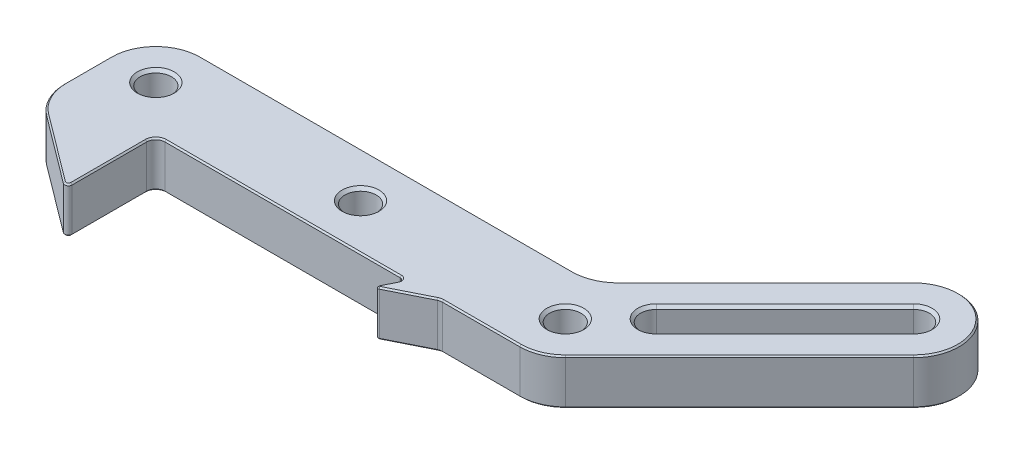
from build123d import *

# Parameters (mm, degrees)
SKETCH1_R           = 2.1828125
BOSS_EXTRUDE1_DEPTH = 6.35
CHAMFER2_SIZE       = 0.396875
CHAMFER3_SIZE       = 0.1984375


with BuildPart() as part:
    # Sketch1 → Boss-Extrude1 (new body)
    with BuildSketch(Plane(origin=(0, 0, 0), x_dir=(1, 0, 0), z_dir=(0, 1, 0))):
        with BuildLine():
            Line((-50.8, -7.62), (-50.8, -18.034))
            ThreePointArc((-50.8, -18.034), (-51.080815493, -18.488369013), (-51.6128, -18.4404))
            Line((-51.6128, -18.4404), (-60.9601016, -11.4299238))
            ThreePointArc((-60.9601016, -11.4299238), (-62.829639478, -9.189819739), (-63.5, -6.350127))
            Line((-63.5, -6.350127), (-63.5, 0.000254))
            ThreePointArc((-63.5, 0.000254), (-61.640202455, 4.490202455), (-57.150254, 6.35))
            Line((-57.150254, 6.35), (-5.260407032, 6.35))
            ThreePointArc((-5.260407032, 6.35), (-2.830464438, 6.833345634), (-0.770458576, 8.209797545))
            Line((-0.770458576, 8.209797545), (19.820563787, 28.800819908))
            ThreePointArc((19.820563787, 28.800819908), (24.310512242, 30.660617452), (28.800819908, 28.800460698))
            ThreePointArc((28.800819908, 28.800460698), (30.660617452, 24.310512242), (28.800819908, 19.820563787))
            Line((28.800819908, 19.820563787), (4.490053666, -4.490202455))
            ThreePointArc((4.490053666, -4.490202455), (2.430047804, -5.866654366), (0.00010521, -6.35))
            Line((0.00010521, -6.35), (-10.812693667, -6.35))
            ThreePointArc((-10.812693667, -6.35), (-11.104479877, -6.383973783), (-11.380654934, -6.484077467))
            Line((-11.380654934, -6.484077467), (-16.780946479, -9.18422324))
            ThreePointArc((-16.780946479, -9.18422324), (-17.074143855, -9.136643856), (-17.121723239, -8.84344648))
            Line((-17.121723239, -8.84344648), (-16.242592252, -7.085184507))
            ThreePointArc((-16.242592252, -7.085184507), (-16.264830655, -6.590928595), (-16.696961265, -6.35))
            Line((-16.696961265, -6.35), (-49.53, -6.35))
            ThreePointArc((-49.53, -6.35), (-50.428025612, -6.721974388), (-50.8, -7.62))
        make_face()
        Circle(SKETCH1_R, mode=Mode.SUBTRACT)
        with Locations((-57.150254, 0.000254)):
            Circle(SKETCH1_R, mode=Mode.SUBTRACT)
        with Locations((-28.574999999, 0.000254)):
            Circle(SKETCH1_R, mode=Mode.SUBTRACT)
        with BuildLine():
            Line((4.806518479, 7.893481521), (22.767030721, 25.853993763))
            ThreePointArc((22.767030721, 25.853993763), (25.853993763, 25.853993763), (25.853993763, 22.767030721))
            Line((25.853993763, 22.767030721), (7.893481521, 4.806518479))
            ThreePointArc((7.893481521, 4.806518479), (4.806518479, 4.806518479), (4.806518479, 7.893481521))
        make_face(mode=Mode.SUBTRACT)
    extrude(amount=BOSS_EXTRUDE1_DEPTH)

    # Chamfer2
    chamfer2_edges = [part.edges().sort_by_distance(p)[0] for p in [
        (-2.1828125, 0, 0),
        (-2.1828125, 6.35, 0),
        (4.806518479, 0, -4.806518479),
        (16.873737642, 0, -13.7867746),
        (25.853993763, 0, -25.853993763),
        (13.7867746, 0, -16.873737642),
        (4.806518479, 6.35, -4.806518479),
        (16.873737642, 6.35, -13.7867746),
        (25.853993763, 6.35, -25.853993763),
        (13.7867746, 6.35, -16.873737642),
        (-59.3330665, 0, -0.000254),
        (-59.3330665, 6.35, -0.000254),
        (-30.757812499, 0, -0.000254),
        (-30.757812499, 6.35, -0.000254),
    ]]
    chamfer(chamfer2_edges, length=CHAMFER2_SIZE)

    # Chamfer3
    chamfer3_edges = [part.edges().sort_by_distance(p)[0] for p in [
        (-2.830464438, 6.35, -6.833345634),
        (-31.205330516, 6.35, -6.35),
        (-61.640202455, 6.35, -4.490202455),
        (24.310766246, 0, -30.660617447),
        (30.660617452, 0, -24.310512242),
        (16.645436787, 0, -7.665180666),
        (2.430047804, 0, 5.866654366),
        (-5.406294229, 0, 6.35),
        (-11.104479877, 0, 6.383973783),
        (-14.080800707, 0, 7.834150354),
        (-17.074143855, 0, 9.136643856),
        (-16.682157746, 0, 7.964315493),
        (-16.264830655, 0, 6.590928595),
        (-63.5, 6.35, 3.1749365),
        (-33.113480633, 0, 6.35),
        (-50.428025612, 0, 6.721974388),
        (-50.8, 0, 12.827),
        (-51.080815493, 0, 18.488369013),
        (-56.2864508, 0, 14.9351619),
        (-62.829639478, 0, 9.189819739),
        (-63.5, 0, 3.1749365),
        (-61.640202455, 0, -4.490202455),
        (-31.205330516, 0, -6.35),
        (-2.830464438, 0, -6.833345634),
        (-62.829639478, 6.35, 9.189819739),
        (9.525052605, 0, -18.505308726),
        (24.310766246, 0, -30.660617447),
        (-56.2864508, 6.35, 14.9351619),
        (-51.080815493, 6.35, 18.488369013),
        (-50.8, 6.35, 12.827),
        (-50.428025612, 6.35, 6.721974388),
        (-33.113480633, 6.35, 6.35),
        (24.310766246, 6.35, -30.660617447),
        (-16.264830655, 6.35, 6.590928595),
        (-16.682157746, 6.35, 7.964315493),
        (-17.074143855, 6.35, 9.136643856),
        (-14.080800707, 6.35, 7.834150354),
        (-11.104479877, 6.35, 6.383973783),
        (-5.406294229, 6.35, 6.35),
        (2.430047804, 6.35, 5.866654366),
        (16.645436787, 6.35, -7.665180666),
        (30.660617452, 6.35, -24.310512242),
        (24.310766246, 6.35, -30.660617447),
        (9.525052605, 6.35, -18.505308726),
    ]]
    chamfer(chamfer3_edges, length=CHAMFER3_SIZE)


solid = part.part
